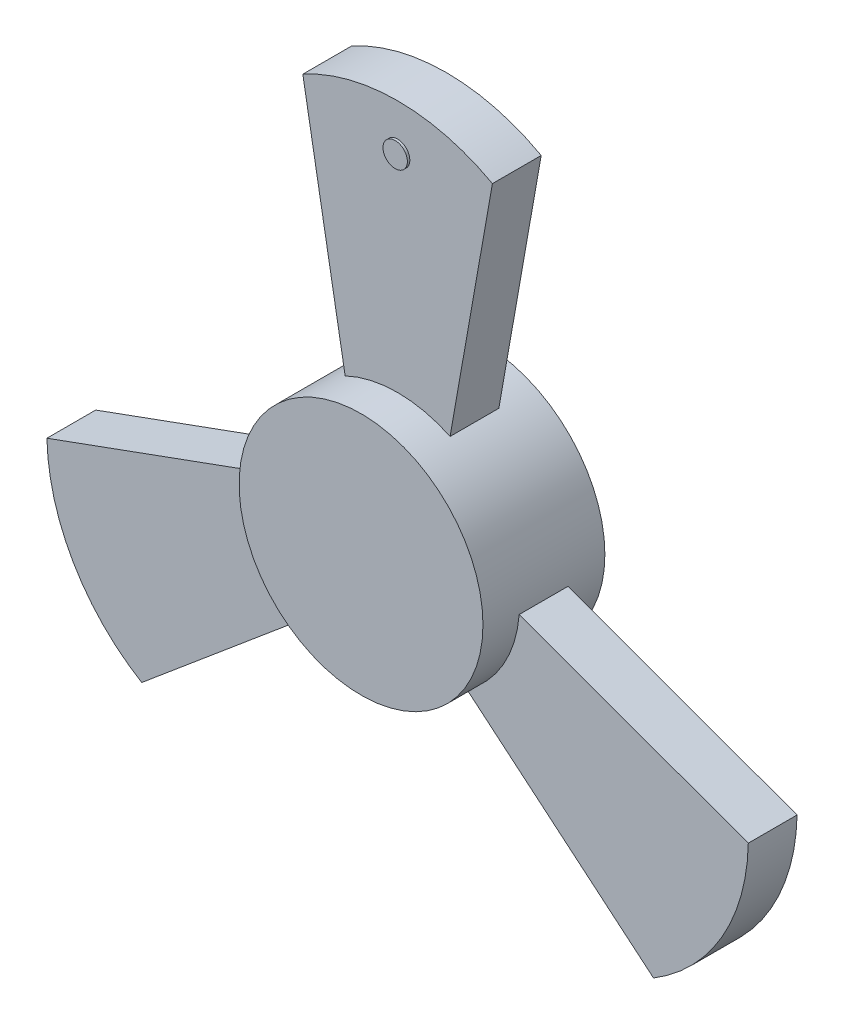
from build123d import *

# Parameters (mm, degrees)
SKETCH1_R           = 50
BOSS_EXTRUDE1_DEPTH = 25
BOSS_EXTRUDE2_DEPTH = 10
SKETCH3_R           = 5
BOSS_EXTRUDE3_DEPTH = 1


with BuildPart() as part:
    # Sketch1 → Boss-Extrude1 (new body, symmetric)
    with BuildSketch(Plane.XY):
        Circle(SKETCH1_R)
    extrude(amount=BOSS_EXTRUDE1_DEPTH, both=True)

    # Sketch2 → Boss-Extrude2 (add, symmetric)
    with BuildSketch(Plane.XY):
        with BuildLine():
            Line((-21.510823847, 45.13628759), (-38.875641614, 143.617062891))
            ThreePointArc((-38.875641614, 143.617062891), (0, 153.617062891), (38.875641614, 143.617062891))
            Line((38.875641614, 143.617062891), (21.510823847, 45.13628759))
            ThreePointArc((21.510823847, 45.13628759), (0, 50), (-21.510823847, 45.13628759))
        make_face()
        with BuildLine():
            Line((104.938204074, -105.475824672), (28.333759762, -41.197063703))
            ThreePointArc((28.333759762, -41.197063703), (43.301270189, -25), (49.844583609, -3.939223887))
            Line((49.844583609, -3.939223887), (143.813845688, -38.14123822))
            ThreePointArc((143.813845688, -38.14123822), (133.036278919, -76.808531446), (104.938204074, -105.475824672))
        make_face()
        with BuildLine():
            Line((-143.813845688, -38.14123822), (-49.844583609, -3.939223887))
            ThreePointArc((-49.844583609, -3.939223887), (-43.301270189, -25), (-28.333759762, -41.197063703))
            Line((-28.333759762, -41.197063703), (-104.938204074, -105.475824672))
            ThreePointArc((-104.938204074, -105.475824672), (-133.036278919, -76.808531446), (-143.813845688, -38.14123822))
        make_face()
    extrude(amount=BOSS_EXTRUDE2_DEPTH, both=True)

    # Sketch3 → Boss-Extrude3 (add, symmetric)
    with BuildSketch(Plane.XY.offset(10)):
        with Locations((0, 135)):
            Circle(SKETCH3_R)
    extrude(amount=BOSS_EXTRUDE3_DEPTH, both=True)


solid = part.part
